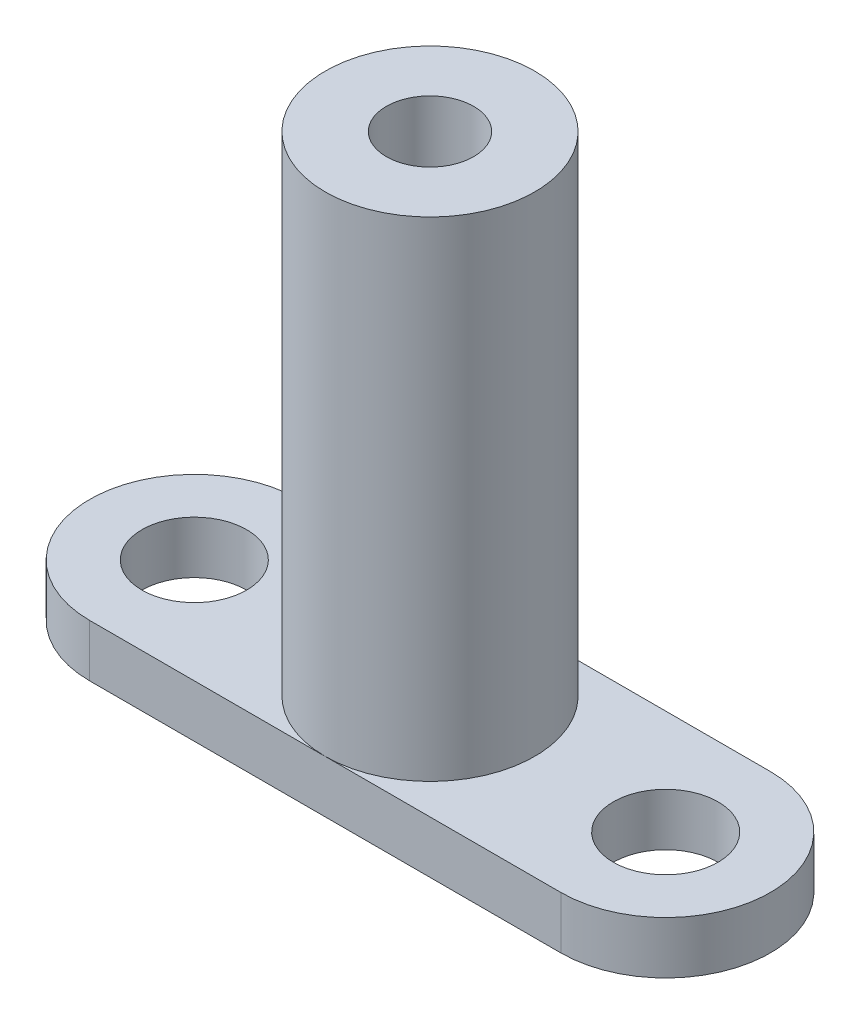
from build123d import *

# Parameters (mm, degrees)
SKETCH_1_R             = 6
EXTRUDE_1_DEPTH        = 3
SKETCH_2_R             = 6
EXTRUDE_2_DEPTH        = 28
HOLE_WIZARD_M6_1_D     = 5
HOLE_WIZARD_M6_1_DEPTH = 12
HOLE_WIZARD_M6_1_TIP   = 1.502151548
SKETCH_6_R             = 3
CUT_EXTRUDE_1_DEPTH    = 10


with BuildPart() as part:
    # 草图1 → 凸台-拉伸1 (new body)
    with BuildSketch(Plane(origin=(0, 0, 0), x_dir=(1, 0, 0), z_dir=(0, 1, 0))):
        with Locations((-13.5, 0)):
            Circle(SKETCH_1_R)
        with BuildLine():
            Line((13.5, 6), (-13.5, 6))
            ThreePointArc((-13.5, 6), (-9.257359313, 4.242640687), (-7.5, 0))
            ThreePointArc((-7.5, 0), (-9.257359313, -4.242640687), (-13.5, -6))
            Line((-13.5, -6), (13.5, -6))
            ThreePointArc((13.5, -6), (7.5, 0), (13.5, 6))
        make_face()
        with Locations((13.5, 0)):
            Circle(SKETCH_1_R)
    extrude(amount=EXTRUDE_1_DEPTH)

    # 草图2 → 凸台-拉伸2 (add)
    with BuildSketch(Plane(origin=(0, 3, 0), x_dir=(1, 0, 0), z_dir=(0, 1, 0))):
        Circle(SKETCH_2_R)
    extrude(amount=EXTRUDE_2_DEPTH)

    # M6 螺纹孔1
    with Locations(Plane(origin=(0, 31, 0), x_dir=(1, 0, 0), z_dir=(0, 1, 0))):
        with Locations((0, 0)):
            Hole(HOLE_WIZARD_M6_1_D / 2, depth=HOLE_WIZARD_M6_1_DEPTH)
            with Locations((0, 0, -(HOLE_WIZARD_M6_1_DEPTH + HOLE_WIZARD_M6_1_TIP / 2))):  # 118° drill point
                Cone(0, HOLE_WIZARD_M6_1_D / 2, HOLE_WIZARD_M6_1_TIP, mode=Mode.SUBTRACT)

    # 草图6 → 切除-拉伸1 (cut)
    with BuildSketch(Plane(origin=(0, 3, 0), x_dir=(1, 0, 0), z_dir=(0, 1, 0))):
        with Locations((-13.5, 0)):
            Circle(SKETCH_6_R)
        with Locations((13.5, 0)):
            Circle(SKETCH_6_R)
    extrude(amount=-CUT_EXTRUDE_1_DEPTH, mode=Mode.SUBTRACT)


solid = part.part
